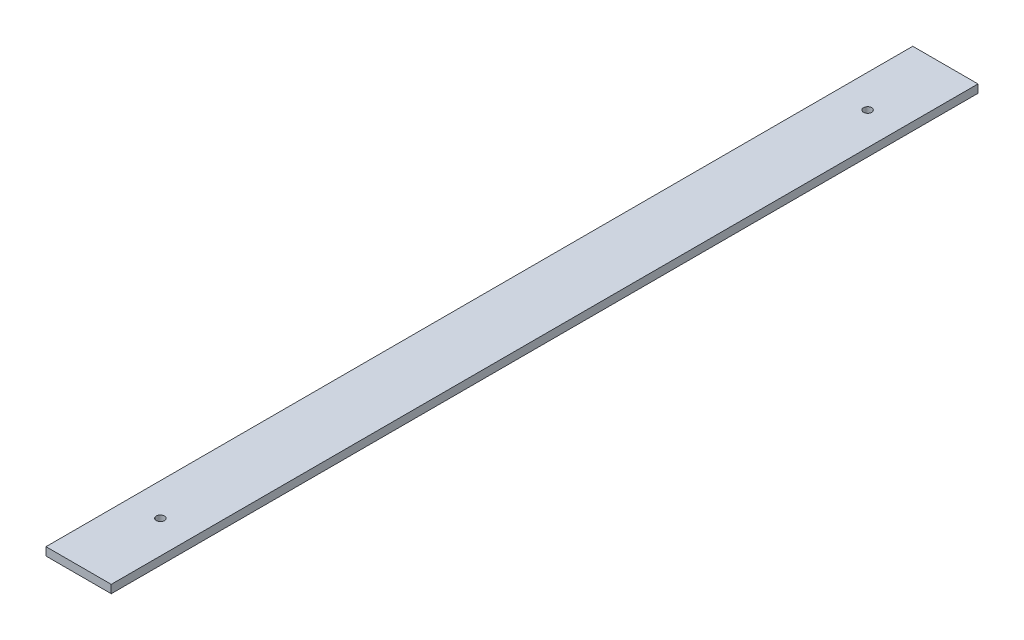
from build123d import *

# Parameters (mm, degrees)
SKETCH4_W             = 200
SKETCH4_H             = 2933.573874127
SKETCH4_R             = 12.5
BOSS_EXTRUDE1_DEPTH   = 25
SKETCH4_H_2           = 2891.000919938
BOSS_EXTRUDE1_2_DEPTH = 25
SKETCH4_H_3           = 2656.8496719
BOSS_EXTRUDE1_3_DEPTH = 25
SKETCH4_H_4           = 2167.26069873
BOSS_EXTRUDE1_4_DEPTH = 25
SKETCH4_H_5           = 1693.636583381
BOSS_EXTRUDE1_5_DEPTH = 25
SKETCH5_W             = 2238.390785376
SKETCH5_H             = 5234.661915406
SKETCH5_W_2           = 2449.892276907
SKETCH5_H_2           = 4952.659926697
CUT_EXTRUDE1_DEPTH    = 26


with BuildPart() as part:
    # Sketch4 → Boss-Extrude1 (new body)
    with BuildSketch(Plane(origin=(0, 0, 0), x_dir=(1, 0, 0), z_dir=(0, 1, 0))):
        with Locations((23132.944645813, -11409.369811035)):
            Rectangle(SKETCH4_W, SKETCH4_H)
        with Locations((23132.944645813, -12678.089615367)):
            Circle(SKETCH4_R, mode=Mode.SUBTRACT)
        with Locations((23132.944645813, -10181.030459334)):
            Circle(SKETCH4_R, mode=Mode.SUBTRACT)
    extrude(amount=BOSS_EXTRUDE1_DEPTH)


with BuildPart() as body_2:
    # Sketch4 → Boss-Extrude1 2 (new body)
    with BuildSketch(Plane(origin=(0, 0, 0), x_dir=(1, 0, 0), z_dir=(0, 1, 0))):
        with Locations((22032.944645813, -11388.083333941)):
            Rectangle(SKETCH4_W, SKETCH4_H_2)
        with Locations((22032.944645813, -12621.228285175)):
            Circle(SKETCH4_R, mode=Mode.SUBTRACT)
        with Locations((22032.944645813, -10181.030459334)):
            Circle(SKETCH4_R, mode=Mode.SUBTRACT)
    extrude(amount=BOSS_EXTRUDE1_2_DEPTH)


with BuildPart() as body_3:
    # Sketch4 → Boss-Extrude1 3 (new body)
    with BuildSketch(Plane(origin=(0, 0, 0), x_dir=(1, 0, 0), z_dir=(0, 1, 0))):
        with Locations((20832.944645813, -11271.007709922)):
            Rectangle(SKETCH4_W, SKETCH4_H_3)
        with Locations((20832.944645813, -12348.754240871)):
            Circle(SKETCH4_R, mode=Mode.SUBTRACT)
        with Locations((20832.944645813, -10181.030459334)):
            Circle(SKETCH4_R, mode=Mode.SUBTRACT)
    extrude(amount=BOSS_EXTRUDE1_3_DEPTH)


with BuildPart() as body_4:
    # Sketch4 → Boss-Extrude1 4 (new body)
    with BuildSketch(Plane(origin=(0, 0, 0), x_dir=(1, 0, 0), z_dir=(0, 1, 0))):
        with Locations((19632.944645813, -11026.213223337)):
            Rectangle(SKETCH4_W, SKETCH4_H_4)
        with Locations((19632.944645813, -11826.915448153)):
            Circle(SKETCH4_R, mode=Mode.SUBTRACT)
        with Locations((19632.944645813, -10181.030459334)):
            Circle(SKETCH4_R, mode=Mode.SUBTRACT)
    extrude(amount=BOSS_EXTRUDE1_4_DEPTH)


with BuildPart() as body_5:
    # Sketch4 → Boss-Extrude1 5 (new body)
    with BuildSketch(Plane(origin=(0, 0, 0), x_dir=(1, 0, 0), z_dir=(0, 1, 0))):
        with Locations((18802.944645813, -10789.401165663)):
            Rectangle(SKETCH4_W, SKETCH4_H_5)
        with Locations((18802.944645813, -11283.669778774)):
            Circle(SKETCH4_R, mode=Mode.SUBTRACT)
        with Locations((18802.944645813, -10181.030459334)):
            Circle(SKETCH4_R, mode=Mode.SUBTRACT)
    extrude(amount=BOSS_EXTRUDE1_5_DEPTH)


with BuildPart() as cut_extrude1_tool:
    # Sketch5 → Cut-Extrude1 (new body, through all)
    with BuildSketch(Plane(origin=(0, 0, 0), x_dir=(1, 0, 0), z_dir=(0, 1, 0))):
        with Locations((22792.145010273, -11127.367822327)):
            Rectangle(SKETCH5_W, SKETCH5_H)
        with Locations((18879.36741694, -11479.870308213)):
            Rectangle(SKETCH5_W_2, SKETCH5_H_2)
    extrude(amount=CUT_EXTRUDE1_DEPTH)


with BuildPart() as part_1:
    add(part.part)

    # Cut-Extrude1: cut by cut_extrude1_tool
    add(cut_extrude1_tool.part, mode=Mode.SUBTRACT)


with BuildPart() as body_2_1:
    add(body_2.part)

    # Cut-Extrude1: cut by cut_extrude1_tool
    add(cut_extrude1_tool.part, mode=Mode.SUBTRACT)


with BuildPart() as body_4_1:
    add(body_4.part)

    # Cut-Extrude1: cut by cut_extrude1_tool
    add(cut_extrude1_tool.part, mode=Mode.SUBTRACT)


with BuildPart() as body_5_1:
    add(body_5.part)

    # Cut-Extrude1: cut by cut_extrude1_tool
    add(cut_extrude1_tool.part, mode=Mode.SUBTRACT)


solid = body_3.part
